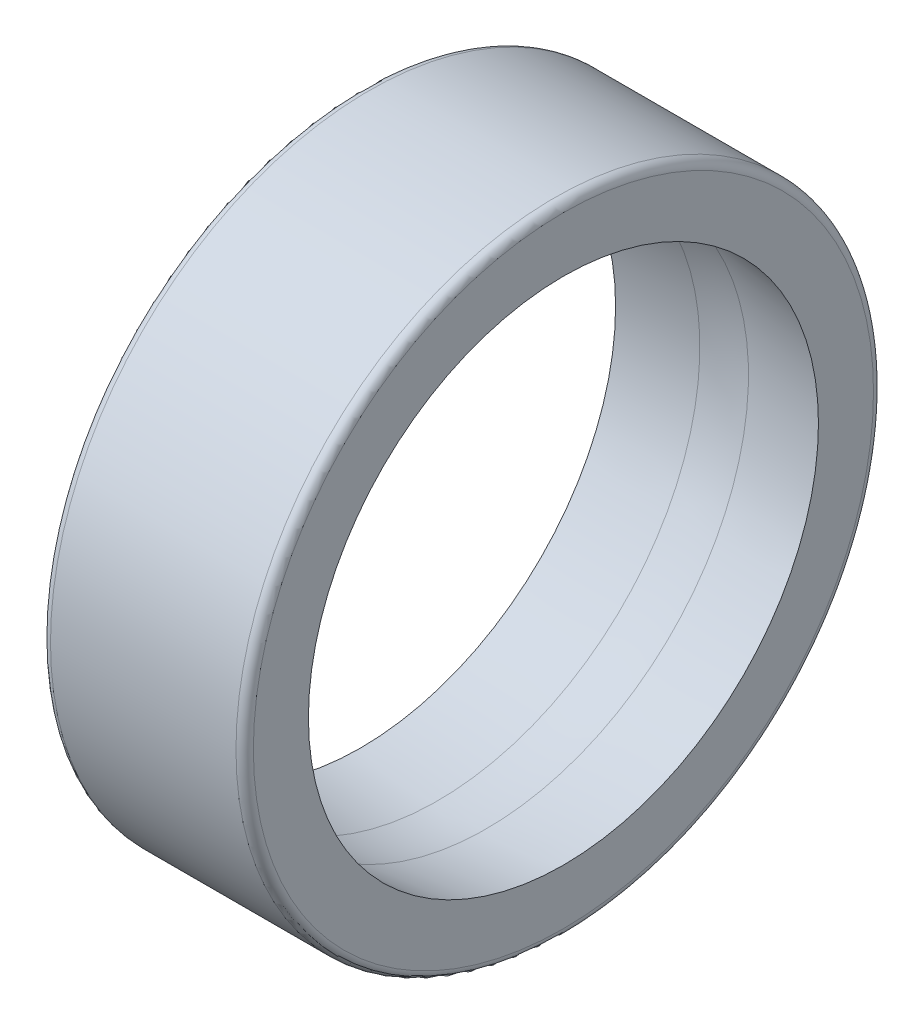
from build123d import *


with BuildPart() as part:
    # Sketch1 → Revolve1 (revolve)
    with BuildSketch(Plane.XY):
        with BuildLine():
            Line((0, 8.8), (2.661204617, 9.046741509))
            ThreePointArc((2.661204617, 9.046741509), (3.5, 9.085544), (4.338795383, 9.046741509))
            Line((4.338795383, 9.046741509), (7, 8.8))
            Line((7, 8.8), (7, 10.7))
            ThreePointArc((7, 10.7), (6.912132034, 10.912132034), (6.7, 11))
            Line((6.7, 11), (0.3, 11))
            ThreePointArc((0.3, 11), (0.087867966, 10.912132034), (0, 10.7))
            Line((0, 10.7), (0, 8.8))
        make_face()
    revolve(axis=Axis((50, 0, 0), (-1, 0, 0)))


solid = part.part
